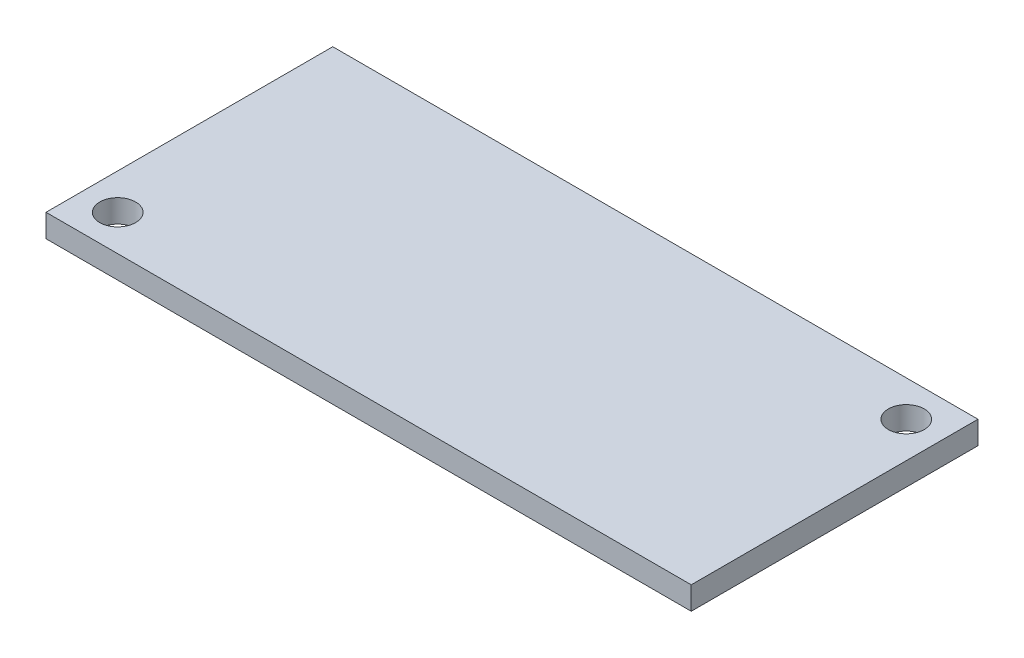
from build123d import *

# Parameters (mm, degrees)
SKETCH1_W           = 45
SKETCH1_H           = 20
BOSS_EXTRUDE1_DEPTH = 1.6
SKETCH8_R           = 1.25
CUT_EXTRUDE3_DEPTH  = 2.6


with BuildPart() as part:
    # Sketch1 → Boss-Extrude1 (new body)
    with BuildSketch(Plane(origin=(0, 0, 0), x_dir=(1, 0, 0), z_dir=(0, 1, 0))):
        Rectangle(SKETCH1_W, SKETCH1_H)
    extrude(amount=BOSS_EXTRUDE1_DEPTH)

    # Sketch8 → Cut-Extrude3 (cut, through all)
    with BuildSketch(Plane(origin=(0, 1.6, 0), x_dir=(1, 0, 0), z_dir=(0, 1, 0))):
        with Locations((-20, -7.5)):
            Circle(SKETCH8_R)
        with Locations((20, 7.5)):
            Circle(SKETCH8_R)
    extrude(amount=-CUT_EXTRUDE3_DEPTH, mode=Mode.SUBTRACT)


solid = part.part
